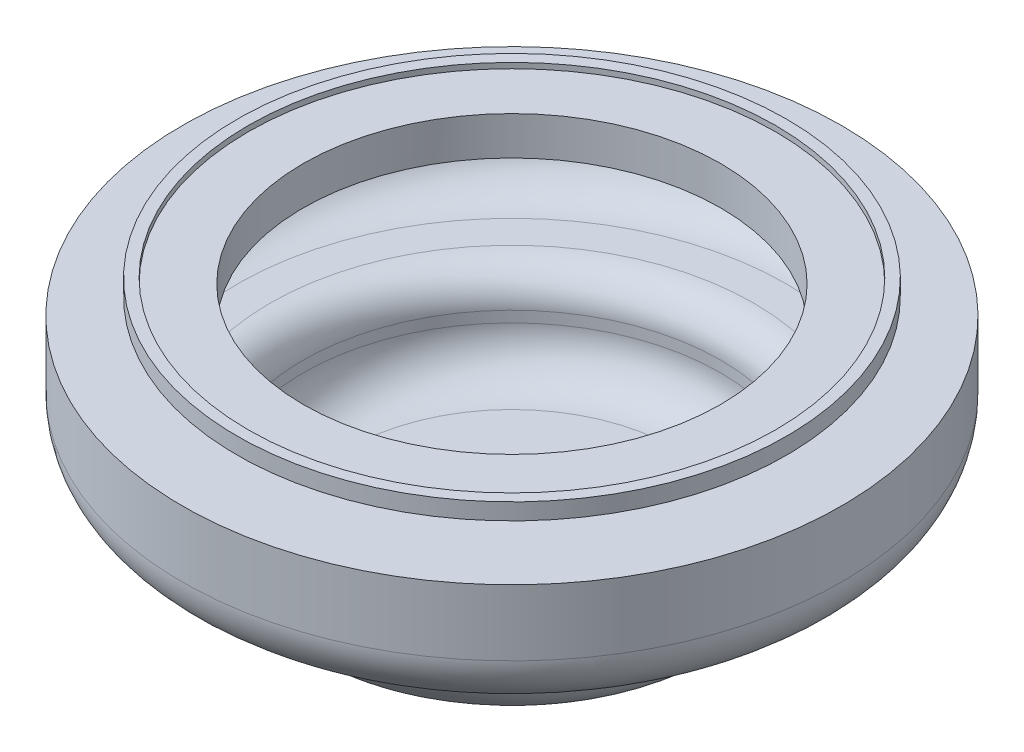
from build123d import *

# Parameters (mm, degrees)
SHELL1_T = -1


with BuildPart() as part:
    # Sketch2 → Revolve1 (revolve)
    with BuildSketch(Plane.XY):
        with BuildLine():
            Line((0, 0), (-25, 0))
            Line((-25, 0), (-25, -1.5))
            Line((-25, -1.5), (-20, -1.5))
            Line((-20, -1.5), (-20, -3))
            Line((-20, -3), (-30, -3))
            Line((-30, -3), (-30, -9))
            ThreePointArc((-30, -9), (-28.535533906, -12.535533906), (-25, -14))
            Line((-25, -14), (-22, -14))
            ThreePointArc((-22, -14), (-20.585786438, -14.585786438), (-20, -16))
            Line((-20, -16), (-20, -17))
            ThreePointArc((-20, -17), (-18.535533906, -20.535533906), (-15, -22))
            Line((-15, -22), (0, -22))
            Line((0, -22), (0, 0))
        make_face()
    revolve(axis=Axis((0, -22, 0), (0, 1, 0)))

    # Shell1
    shell1_openings = [part.faces().sort_by_distance(p)[0] for p in [
        (0, 0, -25),
    ]]
    offset(amount=SHELL1_T, openings=shell1_openings, kind=Kind.INTERSECTION)


solid = part.part
